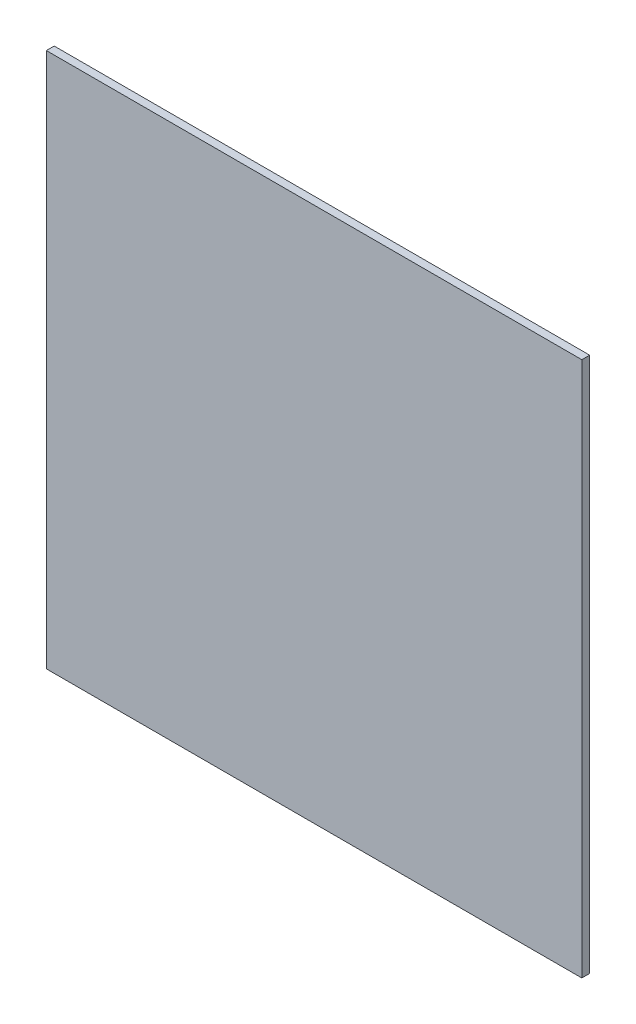
from build123d import *

# Parameters (mm, degrees)
SKETCH_1_W      = 75
SKETCH_1_H      = 75
EXTRUDE_1_DEPTH = 1.1


with BuildPart() as part:
    # 草图1 → 凸台-拉伸1 (new body)
    with BuildSketch(Plane.XY):
        with Locations((12.5, -12.5)):
            Rectangle(SKETCH_1_W, SKETCH_1_H)
    extrude(amount=EXTRUDE_1_DEPTH)


solid = part.part
